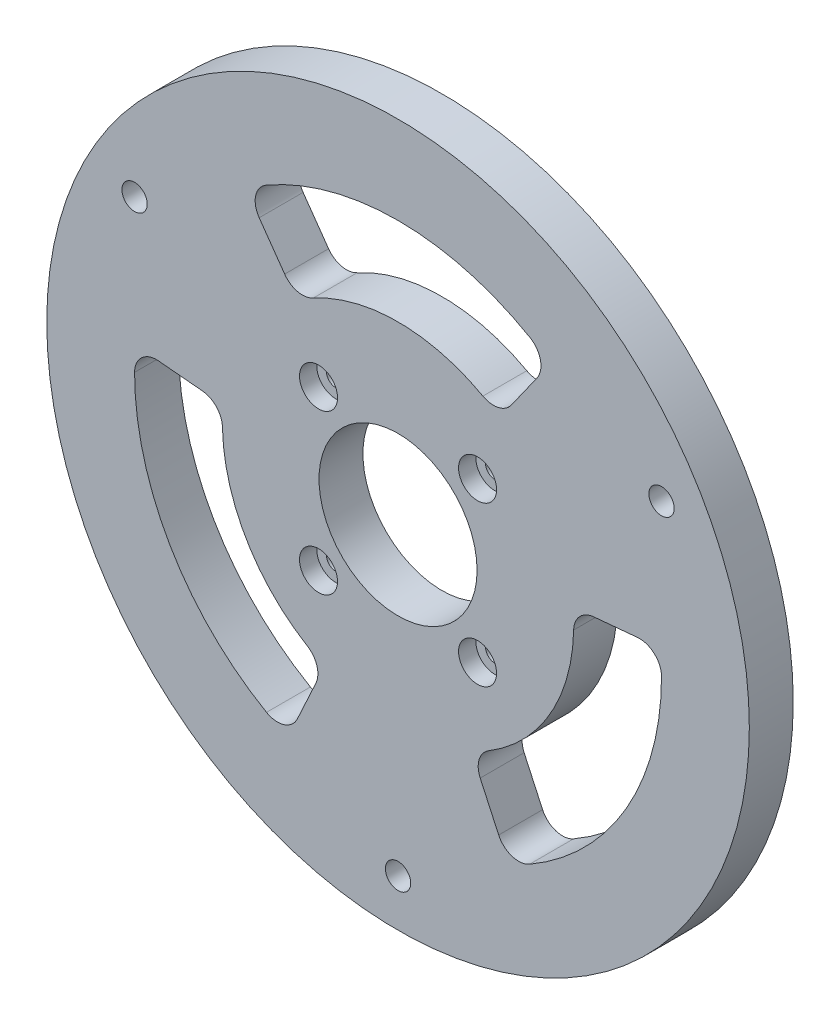
from build123d import *

# Parameters (mm, degrees)
SKETCH1_R                        = 50.8
BOSS_EXTRUDE1_DEPTH              = 6.35
SKETCH2_R                        = 11.43
CUT_EXTRUDE1_DEPTH               = 7.35
CBORE_FOR_M2_5_SHCS1_D           = 2.7
CBORE_FOR_M2_5_SHCS1_DEPTH       = 10.16
CBORE_FOR_M2_5_SHCS1_CBORE_D     = 5.5
CBORE_FOR_M2_5_SHCS1_CBORE_DEPTH = 2.5
CBORE_FOR_M2_5_SHCS1_TIP         = 0.811161836
F_6_CLEARANCE_HOLE1_D            = 3.6576
F_6_CLEARANCE_HOLE1_DEPTH        = 10.16
F_6_CLEARANCE_HOLE1_TIP          = 1.0988539
CUT_EXTRUDE2_DEPTH               = 7.35
FILLET2_R                        = 3.175
CIRPATTERN1_COUNT                = 3
FILLET2_OF_CIRPATTERN1_R         = 3.175


with BuildPart() as part:
    # Sketch1 → Boss-Extrude1 (new body)
    with BuildSketch(Plane.XY):
        Circle(SKETCH1_R)
    extrude(amount=BOSS_EXTRUDE1_DEPTH)

    # Sketch2 → Cut-Extrude1 (cut, through all)
    with BuildSketch(Plane.XY.offset(6.35)):
        Circle(SKETCH2_R)
    extrude(amount=-CUT_EXTRUDE1_DEPTH, mode=Mode.SUBTRACT)

    # CBORE for M2.5 SHCS1
    with Locations(Plane.XY.offset(6.35)):
        with Locations((0, 0), (11.5, 11.5), (-11.5, -11.5), (-11.5, 11.5), (11.5, -11.5)):
            CounterBoreHole(CBORE_FOR_M2_5_SHCS1_D / 2, CBORE_FOR_M2_5_SHCS1_CBORE_D / 2, CBORE_FOR_M2_5_SHCS1_CBORE_DEPTH, depth=CBORE_FOR_M2_5_SHCS1_DEPTH)
            with Locations((0, 0, -(CBORE_FOR_M2_5_SHCS1_DEPTH + CBORE_FOR_M2_5_SHCS1_TIP / 2))):  # 118° drill point
                Cone(0, CBORE_FOR_M2_5_SHCS1_D / 2, CBORE_FOR_M2_5_SHCS1_TIP, mode=Mode.SUBTRACT)

    # #6 Clearance Hole1
    with Locations(Plane.XY.offset(6.35)):
        with Locations((-38.1, 21.997045256), (0, -43.994090512), (38.1, 21.997045256)):
            Hole(F_6_CLEARANCE_HOLE1_D / 2, depth=F_6_CLEARANCE_HOLE1_DEPTH)
            with Locations((0, 0, -(F_6_CLEARANCE_HOLE1_DEPTH + F_6_CLEARANCE_HOLE1_TIP / 2))):  # 118° drill point
                Cone(0, F_6_CLEARANCE_HOLE1_D / 2, F_6_CLEARANCE_HOLE1_TIP, mode=Mode.SUBTRACT)

    # Sketch10 → Cut-Extrude2 (cut, through all)
    with BuildSketch(Plane.XY.offset(6.35)):
        with BuildLine():
            Line((14.664933069, 20.738846113), (21.997399604, 31.108269169))
            ThreePointArc((21.997399604, 31.108269169), (0, 38.1), (-21.997399604, 31.108269169))
            Line((-21.997399604, 31.108269169), (-14.664933069, 20.738846113))
            ThreePointArc((-14.664933069, 20.738846113), (0, 25.4), (14.664933069, 20.738846113))
        make_face()
    cut_extrude2 = extrude(amount=-CUT_EXTRUDE2_DEPTH, mode=Mode.SUBTRACT)

    # Fillet2
    fillet2_edges = [part.edges().sort_by_distance(p)[0] for p in [
        (-21.997399604, 31.108269169, 3.175),
        (21.997399604, 31.108269169, 3.175),
        (14.664933069, 20.738846113, 3.175),
        (-14.664933069, 20.738846113, 3.175),
    ]]
    fillet(fillet2_edges, radius=FILLET2_R)

    # CirPattern1: Cut-Extrude2 ×3 about axis
    cirpattern1_axis = Axis((0, 0, 0), (0, 0, 1))
    for i in range(1, CIRPATTERN1_COUNT):
        add(cut_extrude2.rotate(cirpattern1_axis, i * 360 / CIRPATTERN1_COUNT), mode=Mode.SUBTRACT)

    # Fillet2 of CirPattern1
    fillet2_of_cirpattern1_edges = [part.edges().sort_by_distance(p)[0] for p in [
        (-15.941851566, -34.604441458, 3.175),
        (-37.93925117, 3.49617229, 3.175),
        (-25.292834113, 2.330781526, 3.175),
        (-10.627901044, -23.069627639, 3.175),
        (37.93925117, 3.49617229, 3.175),
        (15.941851566, -34.604441458, 3.175),
        (10.627901044, -23.069627639, 3.175),
        (25.292834113, 2.330781526, 3.175),
    ]]
    fillet(fillet2_of_cirpattern1_edges, radius=FILLET2_OF_CIRPATTERN1_R)


solid = part.part
